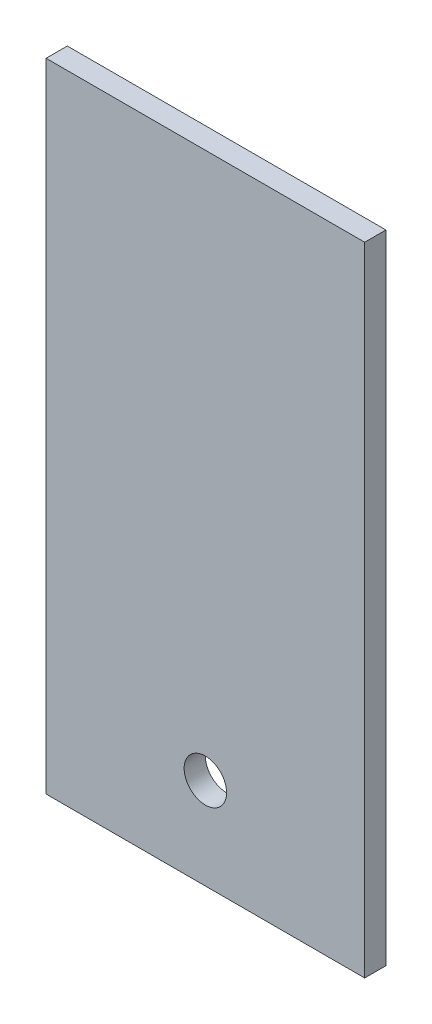
from build123d import *

# Parameters (mm, degrees)
SKETCH1_W           = 150
SKETCH1_H           = 300
SKETCH1_R           = 10
BOSS_EXTRUDE1_DEPTH = 10


with BuildPart() as part:
    # Sketch1 → Boss-Extrude1 (new body)
    with BuildSketch(Plane.XY):
        Rectangle(SKETCH1_W, SKETCH1_H)
        with Locations((0, -107)):
            Circle(SKETCH1_R, mode=Mode.SUBTRACT)
    extrude(amount=BOSS_EXTRUDE1_DEPTH)


solid = part.part
